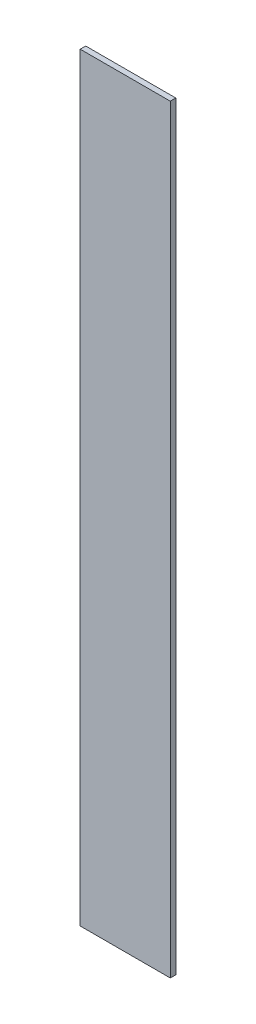
from build123d import *

# Parameters (mm, degrees)
SKETCH1_W           = 81.825506592
SKETCH1_H           = 5
BOSS_EXTRUDE1_DEPTH = 690.01


with BuildPart() as part:
    # Sketch1 → Boss-Extrude1 (new body)
    with BuildSketch(Plane(origin=(0, 0, 0), x_dir=(1, 0, 0), z_dir=(0, 1, 0))):
        with Locations((-11.089564836, 53.304966341)):
            Rectangle(SKETCH1_W, SKETCH1_H)
    extrude(amount=BOSS_EXTRUDE1_DEPTH)


solid = part.part
